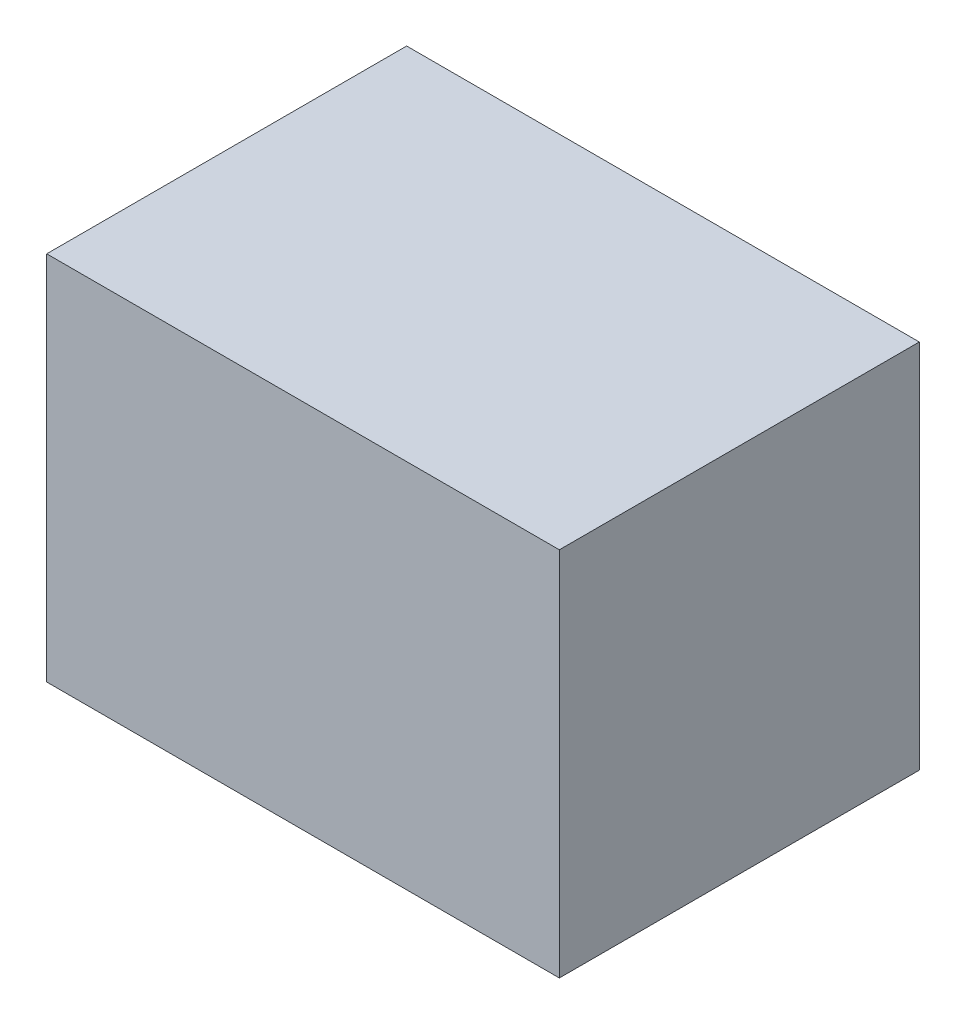
from build123d import *

# Parameters (mm, degrees)
SKETCH1_W           = 4.7
SKETCH1_H           = 3.3
BOSS_EXTRUDE1_DEPTH = 3.4


with BuildPart() as part:
    # Sketch1 → Boss-Extrude1 (new body)
    with BuildSketch(Plane(origin=(0, 0, 0), x_dir=(1, 0, 0), z_dir=(0, 1, 0))):
        with Locations((2.3421875, 0.06875)):
            Rectangle(SKETCH1_W, SKETCH1_H)
    extrude(amount=BOSS_EXTRUDE1_DEPTH)


solid = part.part
